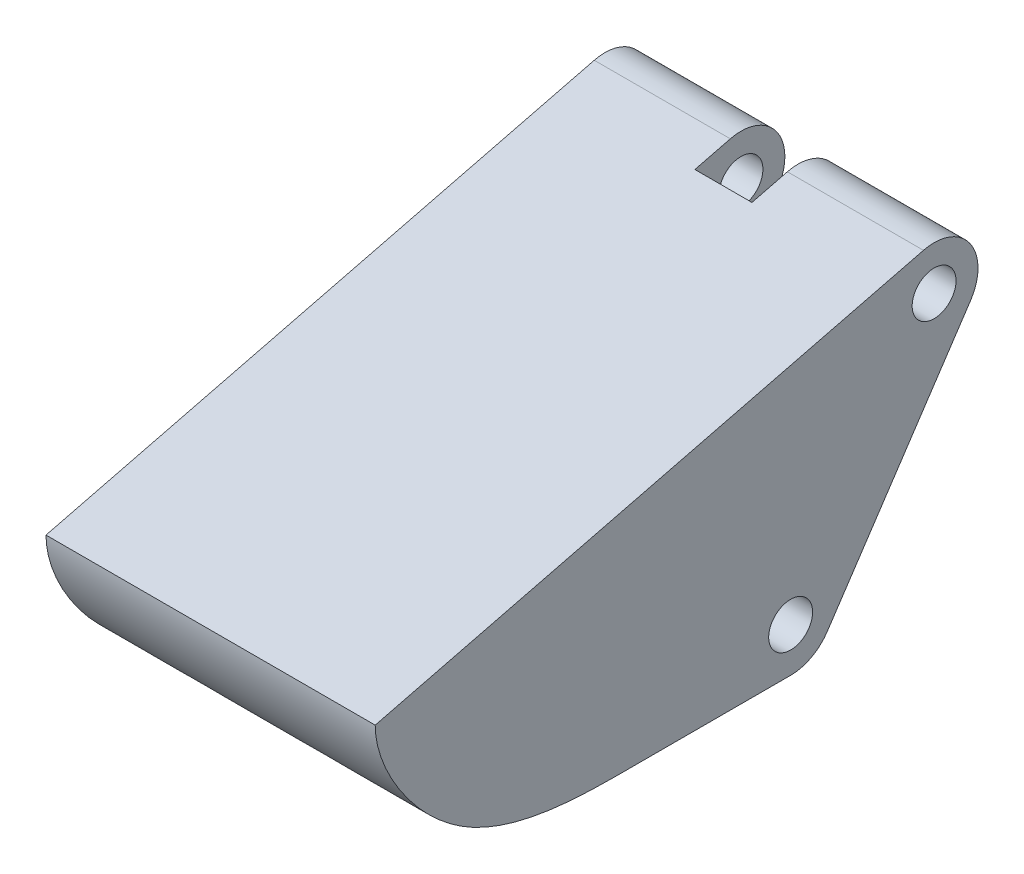
from build123d import *

# Parameters (mm, degrees)
SKETCH2_R           = 1
BOSS_EXTRUDE1_DEPTH = 7.5
SKETCH4_W           = 2.6
SKETCH4_H           = 4.1
CUT_EXTRUDE1_DEPTH  = 15
CUT_EXTRUDE3_DEPTH  = 4


with BuildPart() as part:
    # Sketch2 → Boss-Extrude1 (new body, symmetric)
    with BuildSketch(Plane(origin=(0, 0, 0), x_dir=(0, 0, -1), z_dir=(1, 0, 0))):
        with BuildLine():
            Line((-5.018754521, 6.24531137), (-30, 0))
            add(Edge.make_bspline(
                [(-30, 0), (-30, -1.862010614), (-26.296905553, -7.670881077), (-20.233591891, -7.5), (-18, -7.5)],
                knots=[0, 0, 0, 0, 0.469762973, 1, 1, 1, 1], degree=3))
            Line((-18, -7.5), (-11.070367517, -7.5))
            ThreePointArc((-11.070367517, -7.5), (-10.126651666, -7.263349198), (-9.406266928, -6.609400392))
            Line((-9.406266928, -6.609400392), (-2.869582682, 3.195625977))
            ThreePointArc((-2.869582682, 3.195625977), (-2.89885215, 5.457123243), (-5.018754521, 6.24531137))
        make_face()
        with Locations((-4.533683271, 4.30502637)):
            Circle(SKETCH2_R, mode=Mode.SUBTRACT)
        with Locations((-11.070367517, -5.5)):
            Circle(SKETCH2_R, mode=Mode.SUBTRACT)
    extrude(amount=BOSS_EXTRUDE1_DEPTH, both=True)

    # Sketch4 → Cut-Extrude1 (cut)
    with BuildSketch(Plane(origin=(0, 6.30502637, 0), x_dir=(1, 0, 0), z_dir=(0, 1, 0))):
        with Locations((0, -4.583683271)):
            Rectangle(SKETCH4_W, SKETCH4_H)
    extrude(amount=-CUT_EXTRUDE1_DEPTH, mode=Mode.SUBTRACT)

    # Sketch5 → Cut-Extrude3 (cut)
    with BuildSketch(Plane.XZ.offset(7.5)):
        with BuildLine():
            Line((5, 7.070367517), (-5, 7.070367517))
            Line((-5, 7.070367517), (-5, 14.070367517))
            ThreePointArc((-5, 14.070367517), (0, 16.753742727), (5, 14.070367517))
            Line((5, 14.070367517), (5, 7.070367517))
        make_face()
    extrude(amount=-CUT_EXTRUDE3_DEPTH, mode=Mode.SUBTRACT)


solid = part.part
